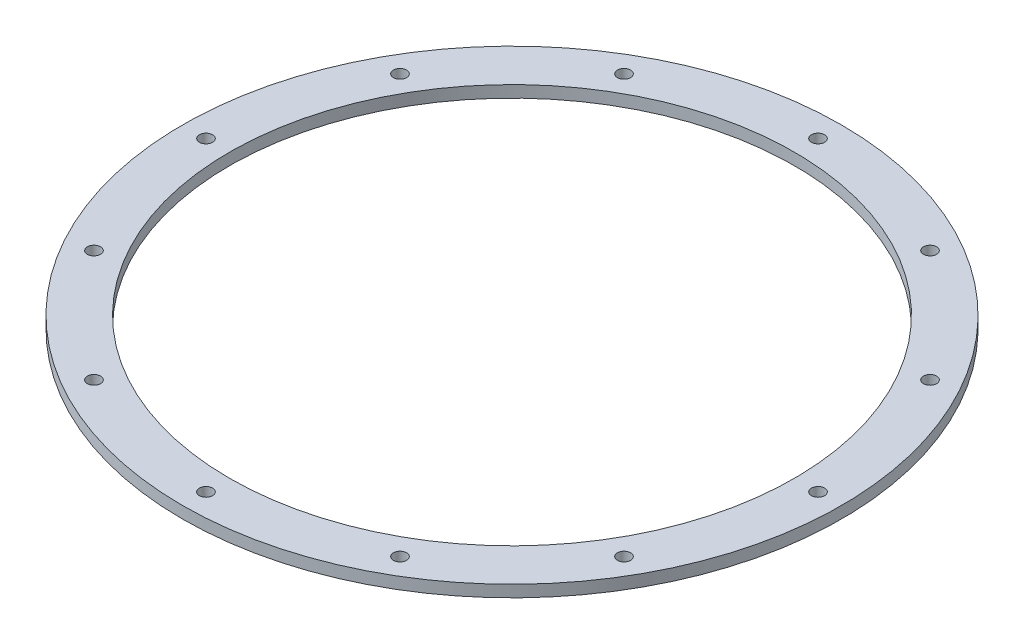
from build123d import *

# Parameters (mm, degrees)
SKETCH1_W                  = 6.35
SKETCH1_H                  = 1.5875
F_50_0_07_DIAMETER_HOLE1_D = 1.778
SCREW_PASSTHROUGHS_COUNT   = 12


with BuildPart() as part:
    # Sketch1 → Main (revolve)
    with BuildSketch(Plane.XY):
        with Locations((-41.275, 0.79375)):
            Rectangle(SKETCH1_W, SKETCH1_H)
    revolve(axis=Axis((0, 55, 0), (0, -1, 0)))

    # #50 (0.07) Diameter Hole1 (through all)
    with Locations(Plane(origin=(0, 0, 0), x_dir=(-1, 0, 0), z_dir=(0, -1, 0))):
        with Locations((41.275, 0)):
            f_50_0_07_diameter_hole1 = Hole(F_50_0_07_DIAMETER_HOLE1_D / 2)

    # Screw Passthroughs: #50 (0.07) Diameter Hole1 ×12 about axis
    screw_passthroughs_axis = Axis((0, 0, 0), (0, 1, 0))
    for i in range(1, SCREW_PASSTHROUGHS_COUNT):
        add(f_50_0_07_diameter_hole1.rotate(screw_passthroughs_axis, i * 360 / SCREW_PASSTHROUGHS_COUNT), mode=Mode.SUBTRACT)


solid = part.part
